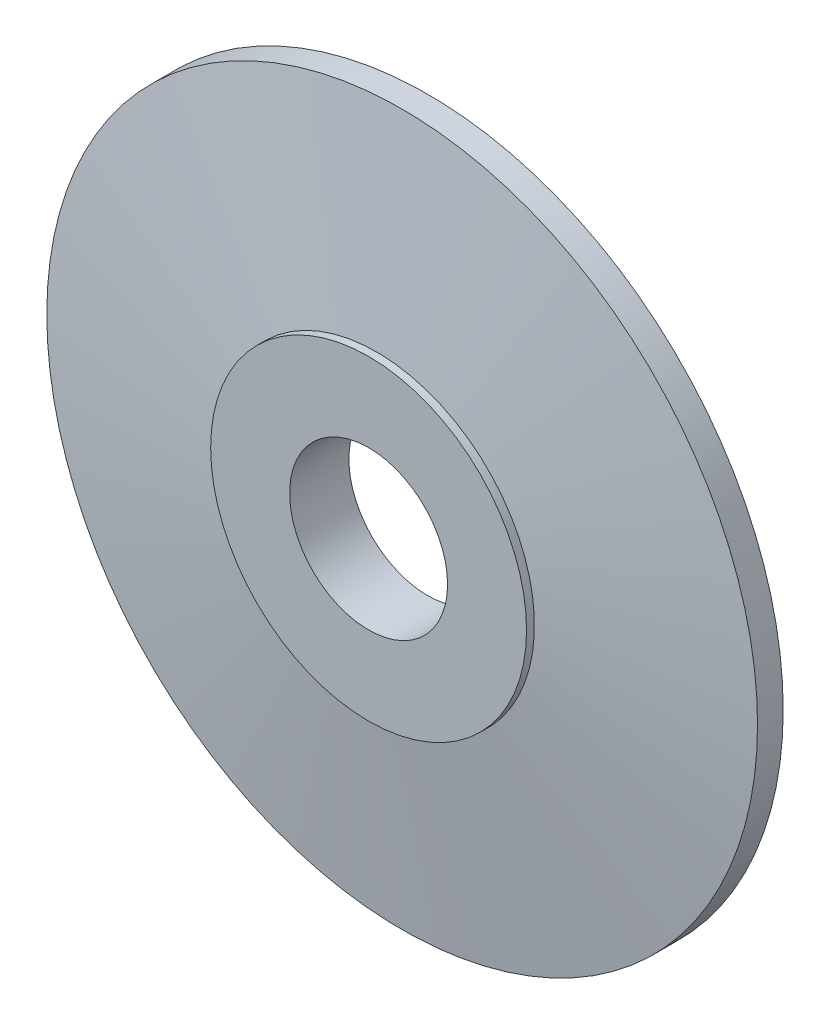
from build123d import *

# Parameters (mm, degrees)
SKETCH_1_R      = 9
SKETCH_1_R_2    = 2
EXTRUDE_1_DEPTH = 1.3
SKETCH_2_R      = 4
SKETCH_2_R_2    = 2
EXTRUDE_2_DEPTH = 0.2


with BuildPart() as part:
    # Эскиз1 → Бобышка-Вытянуть1 (new body)
    with BuildSketch(Plane.XY):
        Circle(SKETCH_1_R)
        Circle(SKETCH_1_R_2, mode=Mode.SUBTRACT)
    extrude(amount=EXTRUDE_1_DEPTH)

    # Эскиз2 → Бобышка-Вытянуть2 (add)
    with BuildSketch(Plane.XY.offset(1.3)):
        Circle(SKETCH_2_R)
        Circle(SKETCH_2_R_2, mode=Mode.SUBTRACT)
    extrude(amount=EXTRUDE_2_DEPTH)

    # Эскиз3 → Вырез-Повернуть1 (revolve, cut)
    with BuildSketch(Plane(origin=(0, 0, 0), x_dir=(1, 0, 0), z_dir=(0, 1, 0))):
        Polygon((-4, -1.3), (-9, -0.65), (-9, -1.3), align=None)
    revolve(axis=Axis((0, 0, 0), (0, 0, 1)), mode=Mode.SUBTRACT)


solid = part.part
